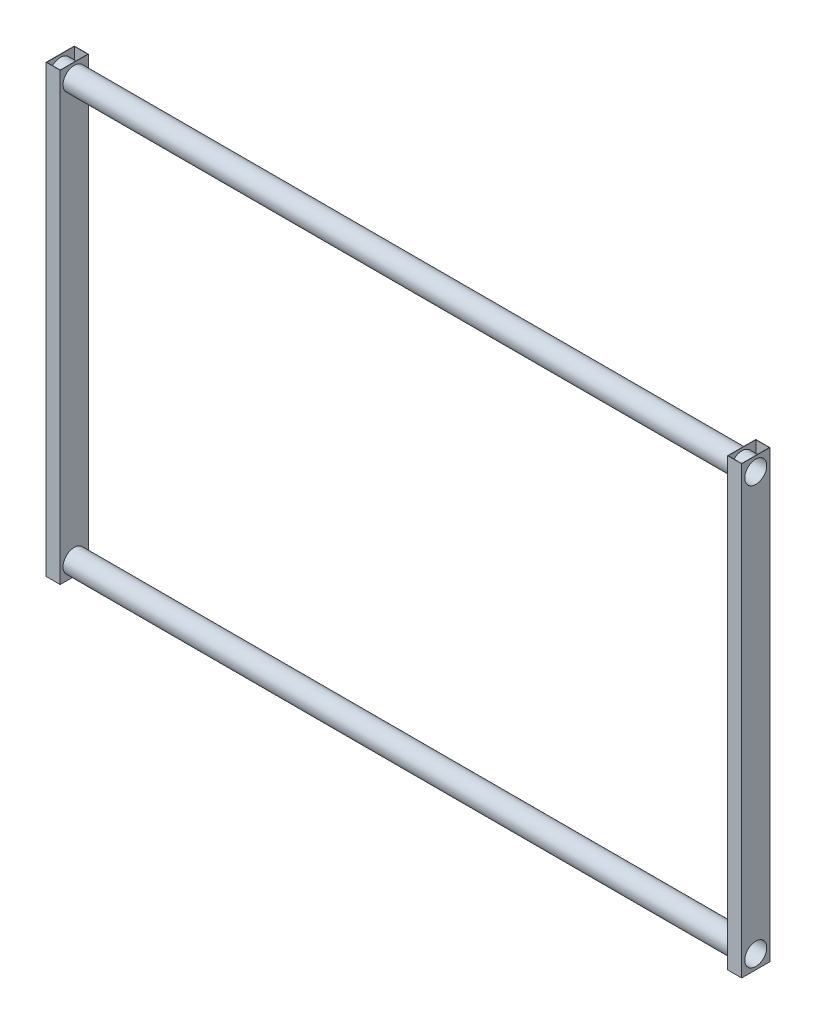
from build123d import *

# Parameters (mm, degrees)
SKETCH3_W             = 50.5
SKETCH3_H             = 101
SKETCH3_W_2           = 48.5
SKETCH3_H_2           = 99
BOSS_EXTRUDE1_DEPTH   = 1600
BOSS_EXTRUDE1_2_DEPTH = 1600
SKETCH8_R             = 39.5
CUT_EXTRUDE1_DEPTH    = 2500
SKETCH9_R             = 40.5
CUT_EXTRUDE2_DEPTH    = 1
SKETCH10_R            = 40.5
CUT_EXTRUDE3_DEPTH    = 1
SKETCH13_R            = 40.5
SKETCH13_R_2          = 39.5
BOSS_EXTRUDE2_DEPTH   = 2497


with BuildPart() as part:
    # Sketch3 → Boss-Extrude1 (new body)
    with BuildSketch(Plane(origin=(0, 0, 0), x_dir=(1, 0, 0), z_dir=(0, 1, 0))):
        with Locations((-25.25, 0)):
            Rectangle(SKETCH3_W, SKETCH3_H)
        with Locations((-25.25, 0)):
            Rectangle(SKETCH3_W_2, SKETCH3_H_2, mode=Mode.SUBTRACT)
    extrude(amount=BOSS_EXTRUDE1_DEPTH)


with BuildPart() as body_2:
    # Sketch3 → Boss-Extrude1 2 (new body)
    with BuildSketch(Plane(origin=(0, 0, 0), x_dir=(1, 0, 0), z_dir=(0, 1, 0))):
        with Locations((2423.25, 0)):
            Rectangle(SKETCH3_W, SKETCH3_H)
        with Locations((2423.25, 0)):
            Rectangle(SKETCH3_W_2, SKETCH3_H_2, mode=Mode.SUBTRACT)
    extrude(amount=BOSS_EXTRUDE1_2_DEPTH)


with BuildPart() as cut_extrude1_tool:
    # Sketch8 → Cut-Extrude1 (new body, through all)
    with BuildSketch(Plane.ZY.offset(50.5)):
        with Locations((0, 50)):
            Circle(SKETCH8_R)
        with Locations((0, 1550)):
            Circle(SKETCH8_R)
    extrude(amount=-CUT_EXTRUDE1_DEPTH)


with BuildPart() as part_1:
    add(part.part)

    # Cut-Extrude1: cut by cut_extrude1_tool
    add(cut_extrude1_tool.part, mode=Mode.SUBTRACT)

    # Sketch9 → Cut-Extrude2 (cut)
    with BuildSketch(Plane(origin=(0, 0, 0), x_dir=(0, 0, -1), z_dir=(1, 0, 0))):
        with Locations((0, 50)):
            Circle(SKETCH9_R)
        with Locations((0, 1550)):
            Circle(SKETCH9_R)
    extrude(amount=-CUT_EXTRUDE2_DEPTH, mode=Mode.SUBTRACT)



with BuildPart() as body_2_1:
    add(body_2.part)

    # Cut-Extrude1: cut by cut_extrude1_tool
    add(cut_extrude1_tool.part, mode=Mode.SUBTRACT)

    # Sketch10 → Cut-Extrude3 (cut)
    with BuildSketch(Plane.ZY.offset(-2398)):
        with Locations((0, 50)):
            Circle(SKETCH10_R)
        with Locations((0, 1550)):
            Circle(SKETCH10_R)
    extrude(amount=-CUT_EXTRUDE3_DEPTH, mode=Mode.SUBTRACT)


with BuildPart() as part_2:
    add(part_1.part)

    add(body_2_1.part)  # Boss-Extrude2 merges body 2
    # Sketch13 → Boss-Extrude2 (add)
    with BuildSketch(Plane.ZY.offset(-2447.5)):
        with Locations((0, 50)):
            Circle(SKETCH13_R)
        with Locations((0, 50)):
            Circle(SKETCH13_R_2, mode=Mode.SUBTRACT)
        with Locations((0, 1550)):
            Circle(SKETCH13_R)
        with Locations((0, 1550)):
            Circle(SKETCH13_R_2, mode=Mode.SUBTRACT)
    extrude(amount=BOSS_EXTRUDE2_DEPTH)


solid = part_2.part
